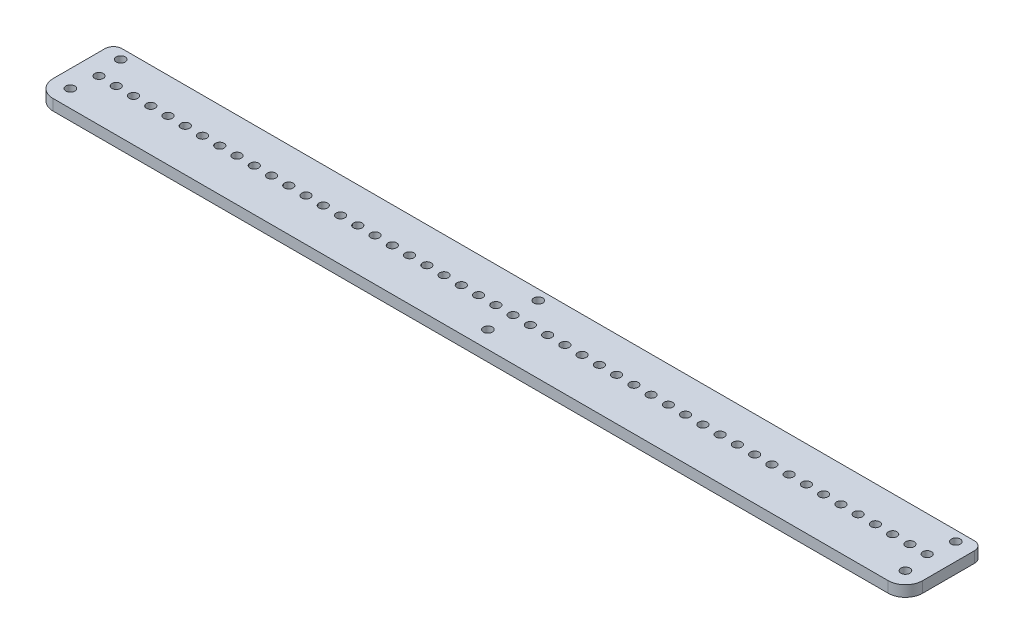
from build123d import *

# Parameters (mm, degrees)
BOSS_EXTRUDE1_DEPTH   = 6.35
M6X1_0_TAPPED_HOLE1_D = 5
LPATTERN1_COUNT       = 49
LPATTERN1_PITCH       = 10
CUT_EXTRUDE1_REACH    = 8.35
SKETCH5_R             = 2.6


with BuildPart() as part:
    # Sketch1 → Boss-Extrude1 (new body)
    with BuildSketch(Plane(origin=(0, 0, 0), x_dir=(1, 0, 0), z_dir=(0, 1, 0))):
        with BuildLine():
            Line((10, 0), (494, 0))
            ThreePointArc((494, 0), (501.071067812, 2.928932188), (504, 10))
            Line((504, 10), (504, 40))
            ThreePointArc((504, 40), (502.535533906, 43.535533906), (499, 45))
            Line((499, 45), (5, 45))
            ThreePointArc((5, 45), (1.464466094, 43.535533906), (0, 40))
            Line((0, 40), (0, 10))
            ThreePointArc((0, 10), (2.928932188, 2.928932188), (10, 0))
        make_face()
    extrude(amount=BOSS_EXTRUDE1_DEPTH)

    # M6x1.0 Tapped Hole1 (through all)
    with Locations(Plane(origin=(0, 6.35, 0), x_dir=(1, 0, 0), z_dir=(0, 1, 0))):
        with Locations((492, 24.6)):
            m6x1_0_tapped_hole1 = Hole(M6X1_0_TAPPED_HOLE1_D / 2)

    # LPattern1: M6x1.0 Tapped Hole1 ×49
    with Locations(*[(-i * LPATTERN1_PITCH, 0, 0) for i in range(1, LPATTERN1_COUNT)]):
        add(m6x1_0_tapped_hole1, mode=Mode.SUBTRACT)

    # Sketch5 → Cut-Extrude1 (cut, up to next)
    with BuildSketch(Plane(origin=(0, 6.35, 0), x_dir=(1, 0, 0), z_dir=(0, 1, 0)), mode=Mode.PRIVATE) as cut_extrude1_sk1:
        with Locations((10, 10)):
            Circle(SKETCH5_R)
    cut_extrude1_tool1 = extrude(cut_extrude1_sk1.sketch, amount=-CUT_EXTRUDE1_REACH, mode=Mode.PRIVATE) & part.part
    add(cut_extrude1_tool1.solids().sort_by_distance((10, 6.35, -10))[0], mode=Mode.SUBTRACT)
    # Sketch5 → Cut-Extrude1 (cut, up to next)
    with BuildSketch(Plane(origin=(0, 6.35, 0), x_dir=(1, 0, 0), z_dir=(0, 1, 0)), mode=Mode.PRIVATE) as cut_extrude1_sk2:
        with Locations((10, 39.2)):
            Circle(SKETCH5_R)
    cut_extrude1_tool2 = extrude(cut_extrude1_sk2.sketch, amount=-CUT_EXTRUDE1_REACH, mode=Mode.PRIVATE) & part.part
    add(cut_extrude1_tool2.solids().sort_by_distance((10, 6.35, -39.2))[0], mode=Mode.SUBTRACT)
    # Sketch5 → Cut-Extrude1 (cut, up to next)
    with BuildSketch(Plane(origin=(0, 6.35, 0), x_dir=(1, 0, 0), z_dir=(0, 1, 0)), mode=Mode.PRIVATE) as cut_extrude1_sk3:
        with Locations((494, 10)):
            Circle(SKETCH5_R)
    cut_extrude1_tool3 = extrude(cut_extrude1_sk3.sketch, amount=-CUT_EXTRUDE1_REACH, mode=Mode.PRIVATE) & part.part
    add(cut_extrude1_tool3.solids().sort_by_distance((494, 6.35, -10))[0], mode=Mode.SUBTRACT)
    # Sketch5 → Cut-Extrude1 (cut, up to next)
    with BuildSketch(Plane(origin=(0, 6.35, 0), x_dir=(1, 0, 0), z_dir=(0, 1, 0)), mode=Mode.PRIVATE) as cut_extrude1_sk4:
        with Locations((494, 39.2)):
            Circle(SKETCH5_R)
    cut_extrude1_tool4 = extrude(cut_extrude1_sk4.sketch, amount=-CUT_EXTRUDE1_REACH, mode=Mode.PRIVATE) & part.part
    add(cut_extrude1_tool4.solids().sort_by_distance((494, 6.35, -39.2))[0], mode=Mode.SUBTRACT)
    # Sketch5 → Cut-Extrude1 (cut, up to next)
    with BuildSketch(Plane(origin=(0, 6.35, 0), x_dir=(1, 0, 0), z_dir=(0, 1, 0)), mode=Mode.PRIVATE) as cut_extrude1_sk5:
        with Locations((252, 10)):
            Circle(SKETCH5_R)
    cut_extrude1_tool5 = extrude(cut_extrude1_sk5.sketch, amount=-CUT_EXTRUDE1_REACH, mode=Mode.PRIVATE) & part.part
    add(cut_extrude1_tool5.solids().sort_by_distance((252, 6.35, -10))[0], mode=Mode.SUBTRACT)
    # Sketch5 → Cut-Extrude1 (cut, up to next)
    with BuildSketch(Plane(origin=(0, 6.35, 0), x_dir=(1, 0, 0), z_dir=(0, 1, 0)), mode=Mode.PRIVATE) as cut_extrude1_sk6:
        with Locations((252, 39.2)):
            Circle(SKETCH5_R)
    cut_extrude1_tool6 = extrude(cut_extrude1_sk6.sketch, amount=-CUT_EXTRUDE1_REACH, mode=Mode.PRIVATE) & part.part
    add(cut_extrude1_tool6.solids().sort_by_distance((252, 6.35, -39.2))[0], mode=Mode.SUBTRACT)


solid = part.part
